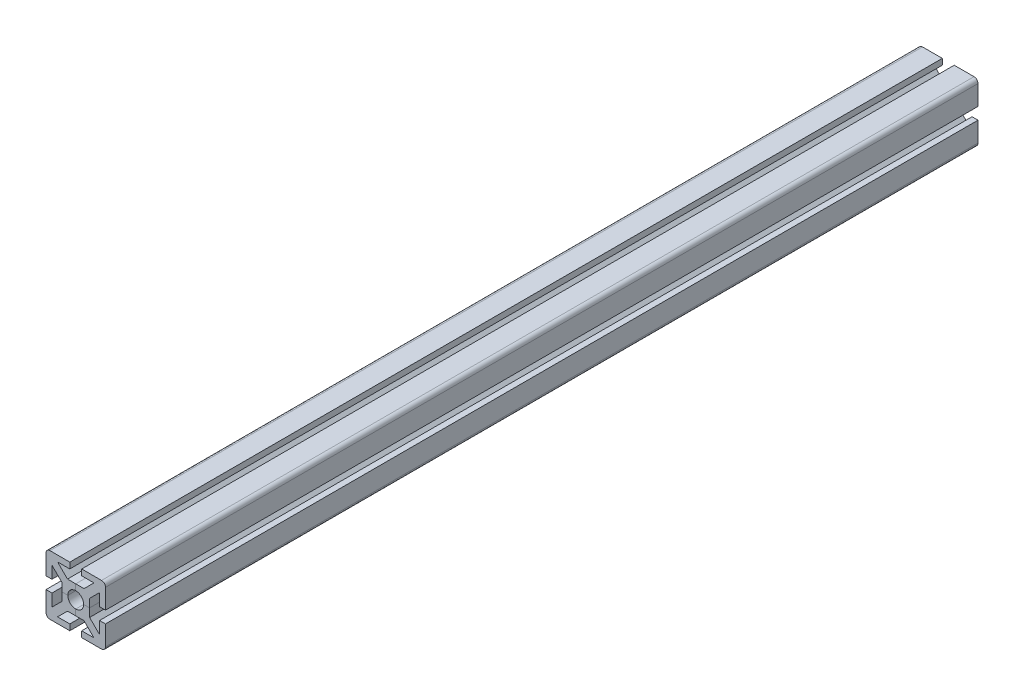
from build123d import *

# Parameters (mm, degrees)
SALIENTE_EXTRUIR1_DEPTH = 220
REDONDEO1_R             = 2
MATRIZC4_COUNT          = 4


with BuildPart() as part:
    # Croquis1 → Saliente-Extruir1 (new body, symmetric)
    with BuildSketch(Plane.XY):
        with BuildLine():
            Line((0, 4), (0, 7))
            Line((0, 7), (4.171572875, 7))
            Line((4.171572875, 7), (9.171572875, 12))
            Line((9.171572875, 12), (3, 12))
            Line((3, 12), (3, 15))
            Line((3, 15), (15, 15))
            Line((15, 15), (2.828427125, 2.828427125))
            ThreePointArc((2.828427125, 2.828427125), (1.530733729, 3.69551813), (0, 4))
        make_face()
    saliente_extruir1 = extrude(amount=SALIENTE_EXTRUIR1_DEPTH, both=True)

    # Simetría1: Saliente-Extruir1 across plane
    add(saliente_extruir1.mirror(Plane(origin=(2.828427125, 2.828427125, 220), x_dir=(0, 0, 1), z_dir=(-0.707106781, 0.707106781, 0))))

    # Redondeo1
    redondeo1_edges = [part.edges().sort_by_distance(p)[0] for p in [
        (15, 15, 0),
    ]]
    fillet(redondeo1_edges, radius=REDONDEO1_R)


with BuildPart() as matrizc4_1:
    # MatrizC4: pattern copy
    add(part.part.rotate(Axis((0, 0, 0), (0, 0, 1)), 1 * 360 / MATRIZC4_COUNT))


with BuildPart() as matrizc4_2:
    # MatrizC4: pattern copy
    add(part.part.rotate(Axis((0, 0, 0), (0, 0, 1)), 2 * 360 / MATRIZC4_COUNT))


with BuildPart() as matrizc4_3:
    # MatrizC4: pattern copy
    add(part.part.rotate(Axis((0, 0, 0), (0, 0, 1)), 3 * 360 / MATRIZC4_COUNT))


solid = Compound([part.part, matrizc4_1.part, matrizc4_2.part, matrizc4_3.part])
